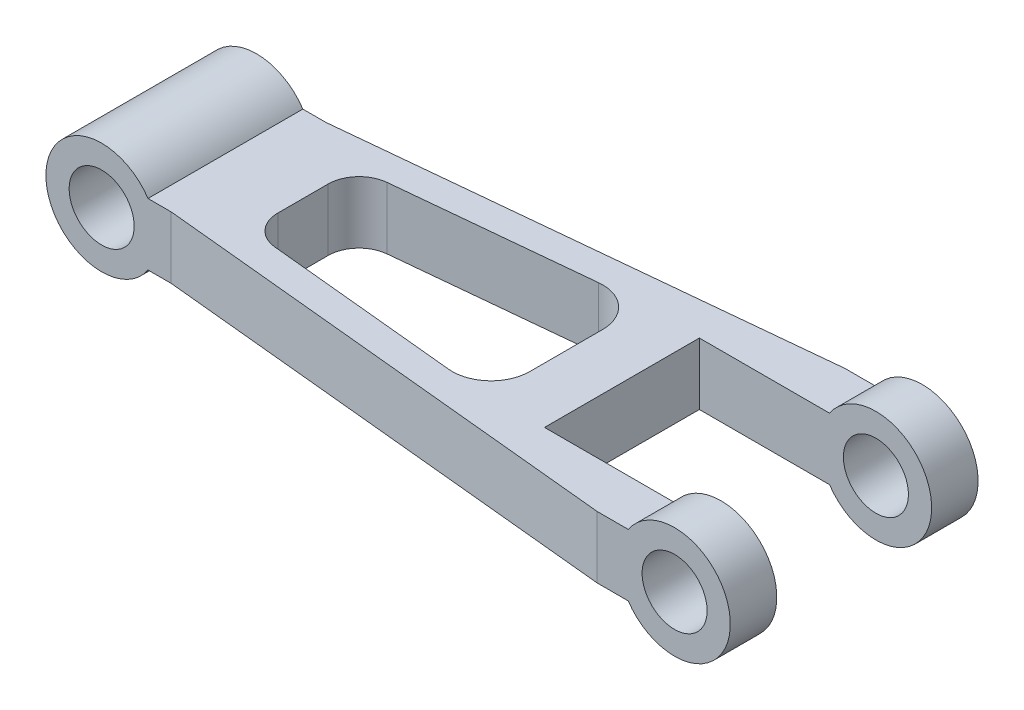
from build123d import *

# Parameters (mm, degrees)
SKETCH1_R               = 21
BOSS_EXTRUDE1_DEPTH     = 160
SKETCH3_W               = 65.933259094
SKETCH3_H               = 30
CUT_EXTRUDE3_DEPTH      = 17
CUT_EXTRUDE3_DEPTH_BACK = 57
CUT_EXTRUDE4_DEPTH      = 17
CUT_EXTRUDE4_DEPTH_BACK = 57
SKETCH6_W               = 300
SKETCH6_H               = 100
CUT_EXTRUDE5_DEPTH      = 17
CUT_EXTRUDE5_DEPTH_BACK = 57


with BuildPart() as part:
    # Sketch1 → Boss-Extrude1 (new body)
    with BuildSketch(Plane.XY):
        with BuildLine():
            Line((29.933259094, 20), (370.066740906, 20))
            ThreePointArc((370.066740906, 20), (436, 0), (370.066740906, -20))
            Line((370.066740906, -20), (29.933259094, -20))
            ThreePointArc((29.933259094, -20), (-36, 0), (29.933259094, 20))
        make_face()
        Circle(SKETCH1_R, mode=Mode.SUBTRACT)
        with Locations((400, 0)):
            Circle(SKETCH1_R, mode=Mode.SUBTRACT)
    extrude(amount=BOSS_EXTRUDE1_DEPTH)

    # Sketch3 → Cut-Extrude3 (cut, two sides)
    with BuildSketch(Plane(origin=(0, 20, 0), x_dir=(1, 0, 0), z_dir=(0, 1, 0))) as cut_extrude3_sk:
        Polygon((29.933259094, 0), (29.933259094, -30), (44.933259094, -30), (350, 0), align=None)
        with Locations((-3.033370453, -15)):
            Rectangle(SKETCH3_W, SKETCH3_H)
        with Locations((-3.033370453, -145)):
            Rectangle(SKETCH3_W, SKETCH3_H)
        Polygon((44.933259094, -130), (29.933259094, -130), (29.933259094, -160), (350, -160), align=None)
    extrude(amount=CUT_EXTRUDE3_DEPTH, mode=Mode.SUBTRACT)
    extrude(cut_extrude3_sk.sketch, amount=-CUT_EXTRUDE3_DEPTH_BACK, mode=Mode.SUBTRACT)

    # Sketch5 → Cut-Extrude4 (cut, two sides)
    with BuildSketch(Plane(origin=(0, 20, 0), x_dir=(1, 0, 0), z_dir=(0, 1, 0))) as cut_extrude4_sk:
        with BuildLine():
            Line((80, -63.737300936), (80, -96.262699064))
            ThreePointArc((80, -96.262699064), (85.181990285, -109.69499552), (98.042658808, -116.166689002))
            Line((98.042658808, -116.166689002), (222.553323511, -128.410960305))
            ThreePointArc((222.553323511, -128.410960305), (241.79037057, -122.053485026), (250, -103.530972882))
            Line((250, -103.530972882), (250, -56.469027118))
            ThreePointArc((250, -56.469027118), (241.79037057, -37.946514974), (222.553323511, -31.589039695))
            Line((222.553323511, -31.589039695), (98.042658808, -43.833310998))
            ThreePointArc((98.042658808, -43.833310998), (85.181990285, -50.30500448), (80, -63.737300936))
        make_face()
    extrude(amount=CUT_EXTRUDE4_DEPTH, mode=Mode.SUBTRACT)
    extrude(cut_extrude4_sk.sketch, amount=-CUT_EXTRUDE4_DEPTH_BACK, mode=Mode.SUBTRACT)

    # Sketch6 → Cut-Extrude5 (cut, two sides)
    with BuildSketch(Plane(origin=(0, 20, 0), x_dir=(1, 0, 0), z_dir=(0, 1, 0))) as cut_extrude5_sk:
        with Locations((436, -80)):
            Rectangle(SKETCH6_W, SKETCH6_H)
    extrude(amount=CUT_EXTRUDE5_DEPTH, mode=Mode.SUBTRACT)
    extrude(cut_extrude5_sk.sketch, amount=-CUT_EXTRUDE5_DEPTH_BACK, mode=Mode.SUBTRACT)


solid = part.part
